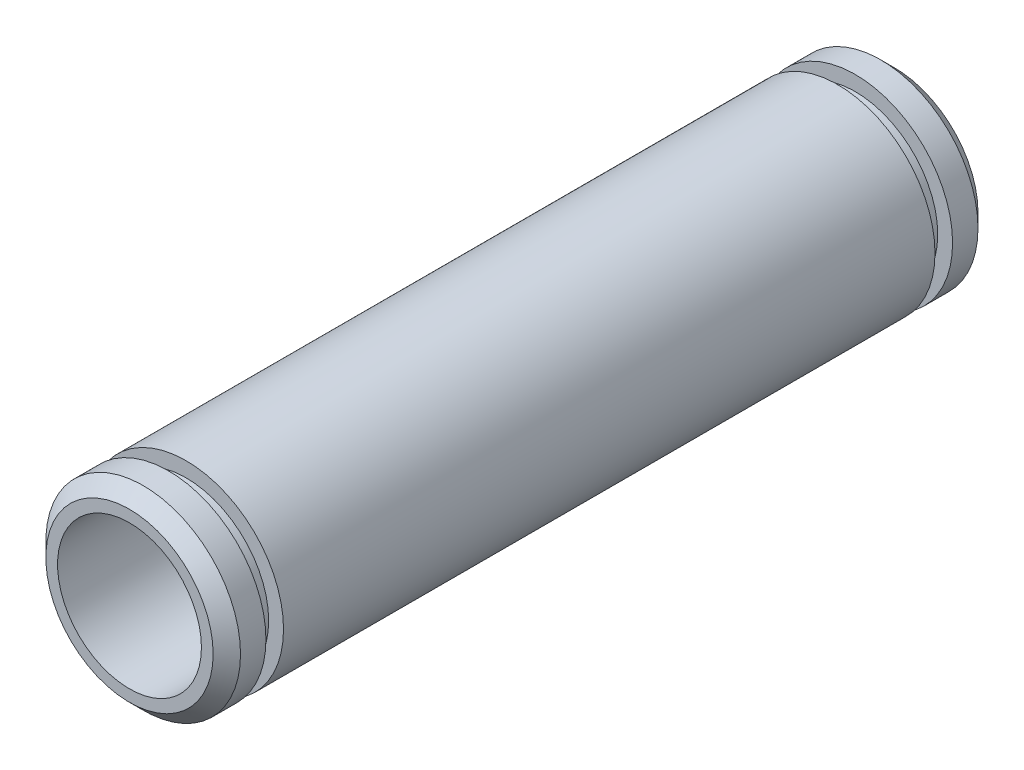
from build123d import *

# Parameters (mm, degrees)
SKETCH1_R           = 6.3246
SKETCH1_R_2         = 4.6736
BOSS_EXTRUDE1_DEPTH = 24.84755
SKETCH2_W           = 0.9652
SKETCH2_H           = 1.143
CHAMFER1_SIZE       = 0.889


with BuildPart() as part:
    # Sketch1 → Boss-Extrude1 (new body, symmetric)
    with BuildSketch(Plane.XY):
        Circle(SKETCH1_R)
        Circle(SKETCH1_R_2, mode=Mode.SUBTRACT)
    extrude(amount=BOSS_EXTRUDE1_DEPTH, both=True)

    # Sketch2 → Cut-Revolve1 (revolve, cut)
    with BuildSketch(Plane(origin=(0, 0, 0), x_dir=(1, 0, 0), z_dir=(0, 1, 0))):
        with Locations((5.842, 21.73605)):
            Rectangle(SKETCH2_W, SKETCH2_H)
    cut_revolve1 = revolve(axis=Axis((0, 0, 1000), (0, 0, -1)), mode=Mode.SUBTRACT)

    # Mirror1: Cut-Revolve1 across plane
    add(cut_revolve1.mirror(Plane.XY), mode=Mode.SUBTRACT)

    # Chamfer1
    chamfer1_edges = [part.edges().sort_by_distance(p)[0] for p in [
        (-6.3246, 0, -24.84755),
        (-6.3246, 0, 24.84755),
    ]]
    chamfer(chamfer1_edges, length=CHAMFER1_SIZE)


solid = part.part
